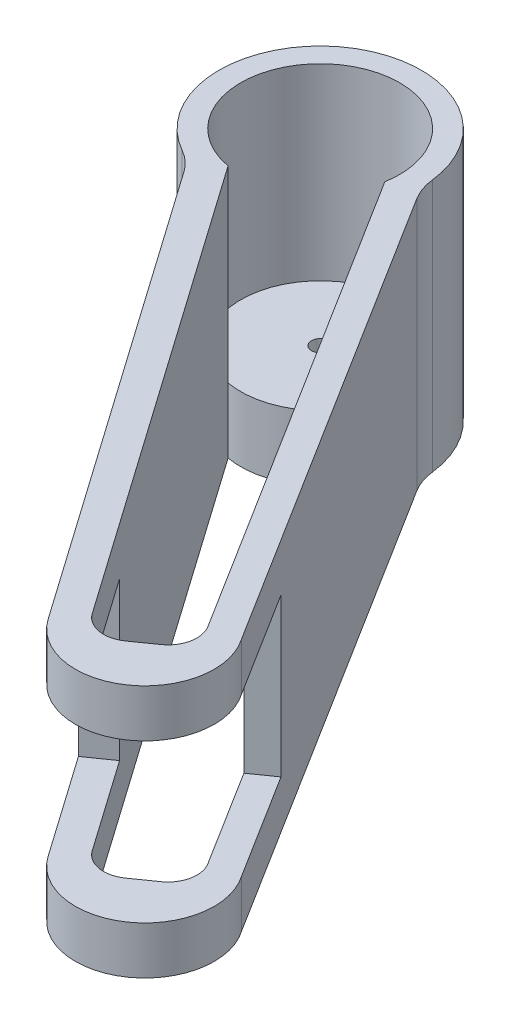
from build123d import *

# Parameters (mm, degrees)
BOSS_EXTRUDE1_DEPTH = 44.45
SKETCH2_R           = 13.97
CUT_EXTRUDE1_DEPTH  = 33.02
SKETCH4_R           = 1.524
CUT_EXTRUDE2_DEPTH  = 11.43
CUT_EXTRUDE4_DEPTH  = 44.45
SKETCH6_W           = 44.799560936
SKETCH6_H           = 27.686
CUT_EXTRUDE5_DEPTH  = 22.225


with BuildPart() as part:
    # Sketch1 → Boss-Extrude1 (new body)
    with BuildSketch(Plane(origin=(0, 0, 0), x_dir=(1, 0, 0), z_dir=(0, 1, 0))):
        with BuildLine():
            Line((-5.43632278, -18.484519804), (50.753878982, -98.550855941))
            ThreePointArc((50.753878982, -98.550855941), (67.749452613, -101.528977989), (70.727574662, -84.533404358))
            Line((70.727574662, -84.533404358), (19.143911472, -2.177551677))
            ThreePointArc((19.143911472, -2.177551677), (18.167371728, -0.148266421), (17.661854227, 2.046290613))
            ThreePointArc((17.661854227, 2.046290613), (-9.829221355, 14.816032112), (-8.751716681, -15.476945924))
            ThreePointArc((-8.751716681, -15.476945924), (-6.926324763, -16.795874604), (-5.43632278, -18.484519804))
        make_face()
    extrude(amount=BOSS_EXTRUDE1_DEPTH)

    # Sketch2 → Cut-Extrude1 (cut)
    with BuildSketch(Plane(origin=(0, 44.45, 0), x_dir=(1, 0, 0), z_dir=(0, 1, 0))):
        Circle(SKETCH2_R)
    extrude(amount=-CUT_EXTRUDE1_DEPTH, mode=Mode.SUBTRACT)

    # Sketch4 → Cut-Extrude2 (cut)
    with BuildSketch(Plane.XZ):
        Circle(SKETCH4_R)
    extrude(amount=-CUT_EXTRUDE2_DEPTH, mode=Mode.SUBTRACT)

    # Sketch5 → Cut-Extrude4 (cut)
    with BuildSketch(Plane(origin=(0, 44.45, 0), x_dir=(1, 0, 0), z_dir=(0, 1, 0))):
        with BuildLine():
            Line((-2.419955599, -13.758804995), (53.761320997, -93.799464422))
            ThreePointArc((53.761320997, -93.799464422), (57.042861973, -95.884776857), (60.837800413, -95.038915544))
            Line((60.837800413, -95.038915544), (64.500597561, -92.467964465))
            ThreePointArc((64.500597561, -92.467964465), (66.561253196, -89.317108071), (65.887093565, -85.613095861))
            Line((65.887093565, -85.613095861), (13.761291875, -2.405773456))
            ThreePointArc((13.761291875, -2.405773456), (8.023671754, -11.435977946), (-2.419955599, -13.758804995))
        make_face()
    extrude(amount=-CUT_EXTRUDE4_DEPTH, mode=Mode.SUBTRACT)

    # Sketch6 → Cut-Extrude5 (cut, symmetric)
    with BuildSketch(Plane(origin=(63.31167299, 0, 90.199232956), x_dir=(-0.8184971, 0, 0.574510659), z_dir=(-0.574510659, 0, -0.8184971))):
        with Locations((1.370623881, 22.225)):
            Rectangle(SKETCH6_W, SKETCH6_H)
    extrude(amount=CUT_EXTRUDE5_DEPTH, both=True, mode=Mode.SUBTRACT)


solid = part.part
